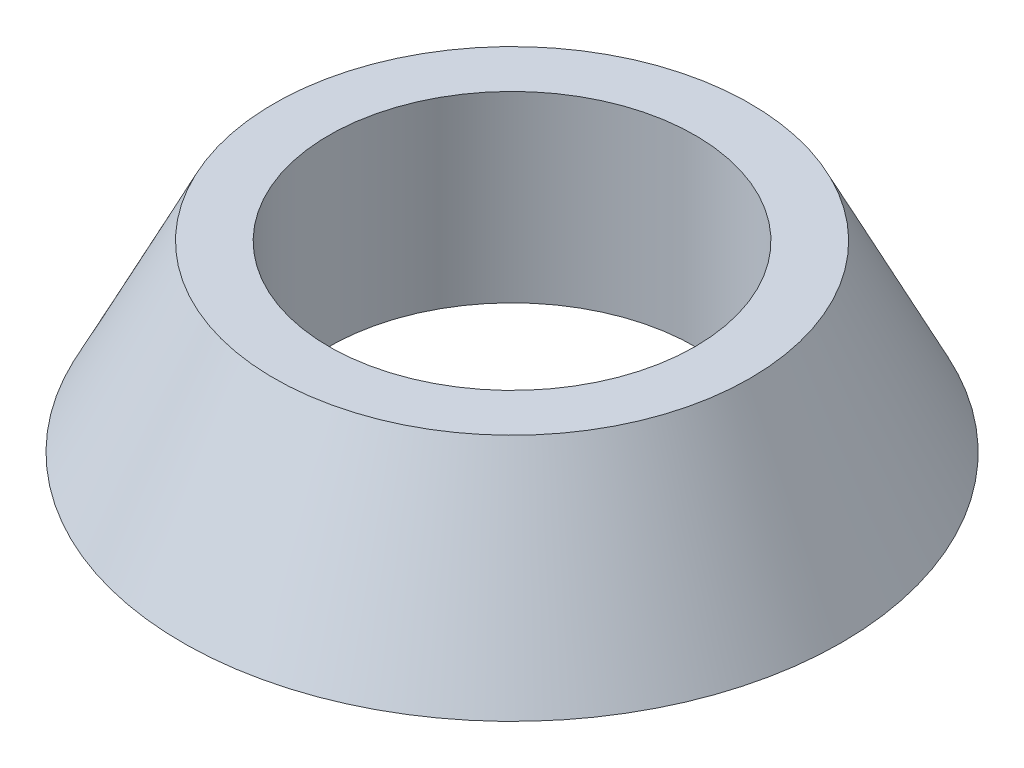
from build123d import *


with BuildPart() as part:
    # Szkic1 → Obrót1 (revolve)
    with BuildSketch(Plane.XY):
        Polygon((5, 0), (5, 5), (6.5, 5), (9, 0), align=None)
    revolve(axis=Axis((0, 0, 0), (0, 1, 0)))


solid = part.part
